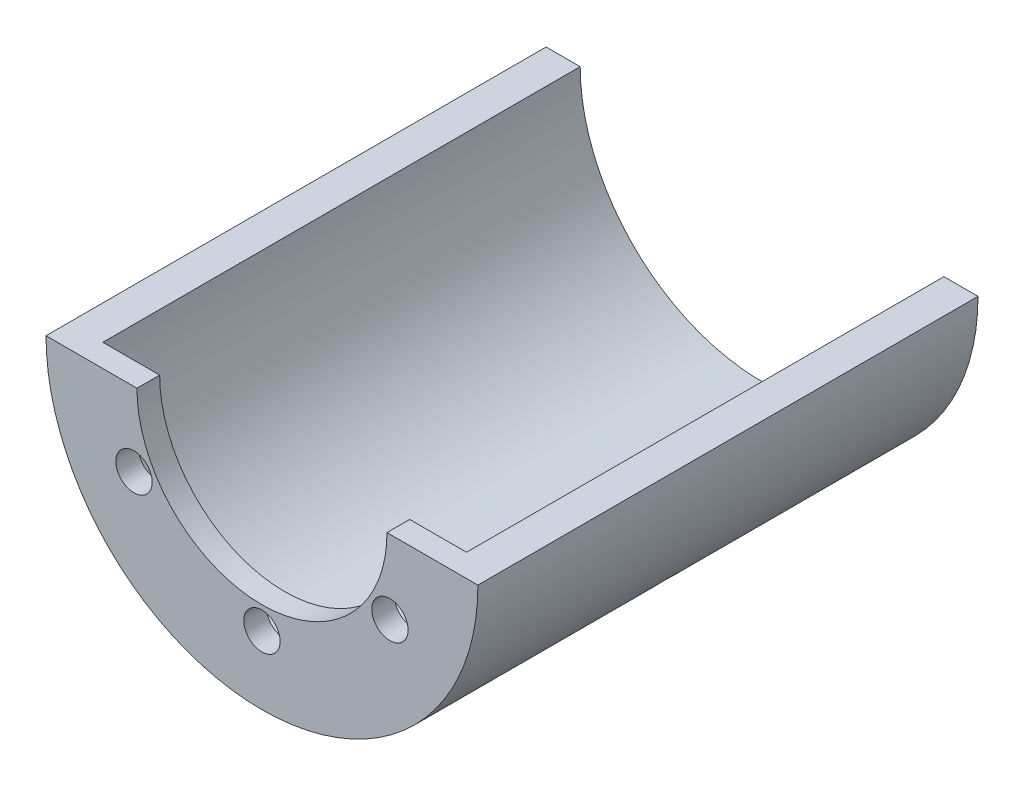
from build123d import *

# Parameters (mm, degrees)
SKETCH1_R                       = 9.5
BOSS_EXTRUDE1_DEPTH             = 21
SKETCH2_R                       = 8
CUT_EXTRUDE1_DEPTH              = 22
SKETCH4_W                       = 19
SKETCH4_H                       = 9.5
CUT_EXTRUDE2_DEPTH              = 22
BOSS_EXTRUDE3_DEPTH             = 1
SKETCH7_R                       = 0.5
CUT_EXTRUDE8_DEPTH              = 0.5
CIRPATTERN1_COUNT               = 2
CIRPATTERN1_ANGLE               = 45
CIRPATTERN1_THE_OTHER_WAY_COUNT = 2
CIRPATTERN1_THE_OTHER_WAY_ANGLE = 45
SKETCH8_R                       = 5.5
CUT_EXTRUDE9_DEPTH              = 23.0000001
SKETCH9_R                       = 0.8
CUT_EXTRUDE10_DEPTH             = 2.0000001
CIRPATTERN2_COUNT               = 6


with BuildPart() as part:
    # Sketch1 → Boss-Extrude1 (new body)
    with BuildSketch(Plane.XY):
        Circle(SKETCH1_R)
    extrude(amount=BOSS_EXTRUDE1_DEPTH)

    # Sketch2 → Cut-Extrude1 (cut, through all)
    with BuildSketch(Plane.XY.offset(21)):
        Circle(SKETCH2_R)
    extrude(amount=-CUT_EXTRUDE1_DEPTH, mode=Mode.SUBTRACT)

    # Sketch4 → Cut-Extrude2 (cut, through all)
    with BuildSketch(Plane.XY.offset(21)):
        with Locations((0, 4.75)):
            Rectangle(SKETCH4_W, SKETCH4_H)
    extrude(amount=-CUT_EXTRUDE2_DEPTH, mode=Mode.SUBTRACT)

    # Sketch5 → Boss-Extrude3 (add)
    with BuildSketch(Plane.XY.offset(21)):
        with BuildLine():
            ThreePointArc((8, 0), (0, -8), (-8, 0))
            Line((-8, 0), (-9.5, 0))
            ThreePointArc((-9.5, 0), (0, -9.5), (9.5, 0))
            Line((9.5, 0), (8, 0))
        make_face()
        with BuildLine():
            Line((8, 0), (-8, 0))
            ThreePointArc((-8, 0), (0, -8), (8, 0))
        make_face()
    extrude(amount=BOSS_EXTRUDE3_DEPTH)

    # Sketch7 → Cut-Extrude8 (cut)
    with BuildSketch(Plane(origin=(0, -9.75, 0), x_dir=(1, 0, 0), z_dir=(0, 1, 0))):
        with Locations((0, -11)):
            Circle(SKETCH7_R)
        with Locations((0, 4)):
            Circle(SKETCH7_R)
        with Locations((0, -26)):
            Circle(SKETCH7_R)
    cut_extrude8 = extrude(amount=CUT_EXTRUDE8_DEPTH, mode=Mode.SUBTRACT)

    # CirPattern1: Cut-Extrude8 ×2 about axis
    cirpattern1_axis = Axis((0, 0, 0), (0, 0, -1))
    for i in range(1, CIRPATTERN1_COUNT):
        add(cut_extrude8.rotate(cirpattern1_axis, i * CIRPATTERN1_ANGLE / (CIRPATTERN1_COUNT - 1)), mode=Mode.SUBTRACT)

    # CirPattern1 the other way: Cut-Extrude8 ×2 about axis
    cirpattern1_the_other_way_axis = Axis((0, 0, 0), (0, 0, 1))
    for i in range(1, CIRPATTERN1_THE_OTHER_WAY_COUNT):
        add(cut_extrude8.rotate(cirpattern1_the_other_way_axis, i * CIRPATTERN1_THE_OTHER_WAY_ANGLE / (CIRPATTERN1_THE_OTHER_WAY_COUNT - 1)), mode=Mode.SUBTRACT)

    # Sketch8 → Cut-Extrude9 (cut, through all)
    with BuildSketch(Plane.XY.offset(22)):
        Circle(SKETCH8_R)
    extrude(amount=-CUT_EXTRUDE9_DEPTH, mode=Mode.SUBTRACT)

    # Sketch9 → Cut-Extrude10 (cut, through all)
    with BuildSketch(Plane(origin=(0, 0, 21), x_dir=(-1, 0, 0), z_dir=(0, 0, -1))):
        with Locations((0, -6.5)):
            Circle(SKETCH9_R)
    cut_extrude10 = extrude(amount=-CUT_EXTRUDE10_DEPTH, mode=Mode.SUBTRACT)

    # CirPattern2: Cut-Extrude10 ×6 about axis
    cirpattern2_axis = Axis((0, 0, 0), (0, 0, 1))
    for i in range(1, CIRPATTERN2_COUNT):
        add(cut_extrude10.rotate(cirpattern2_axis, i * 360 / CIRPATTERN2_COUNT), mode=Mode.SUBTRACT)


solid = part.part
